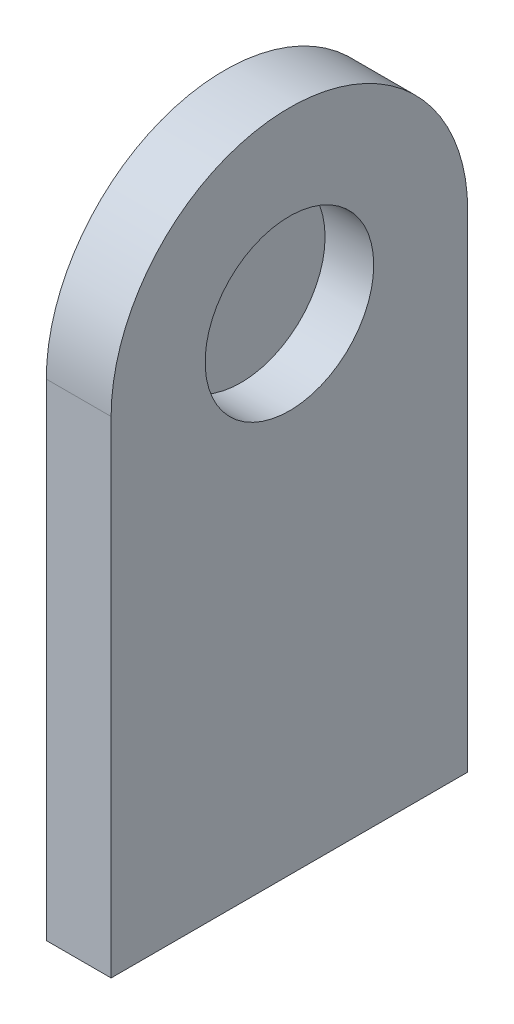
from build123d import *

# Parameters (mm, degrees)
BOSS_EXTRUDE1_DEPTH             = 20
SKETCH3_R                       = 26
CUT_EXTRUDE1_DEPTH              = 15
TAP_DRILL_FOR_M6X1_0_TAP2_D     = 5
TAP_DRILL_FOR_M6X1_0_TAP2_DEPTH = 40
TAP_DRILL_FOR_M6X1_0_TAP2_TIP   = 1.502151548


with BuildPart() as part:
    # Sketch2 → Boss-Extrude1 (new body)
    with BuildSketch(Plane(origin=(0, 0, 0), x_dir=(0, 0, -1), z_dir=(1, 0, 0))):
        with BuildLine():
            Line((55, -75), (55, 75))
            ThreePointArc((55, 75), (0, 20), (-55, 75))
            Line((-55, 75), (-55, -75))
            Line((-55, -75), (55, -75))
        make_face()
        with BuildLine():
            ThreePointArc((-55, 75), (0, 20), (55, 75))
            Line((55, 75), (-55, 75))
        make_face()
        with BuildLine():
            Line((-55, 75), (55, 75))
            ThreePointArc((55, 75), (0, 130), (-55, 75))
        make_face()
    extrude(amount=BOSS_EXTRUDE1_DEPTH)

    # Sketch3 → Cut-Extrude1 (cut)
    with BuildSketch(Plane(origin=(20, 0, 0), x_dir=(0, 0, -1), z_dir=(1, 0, 0))):
        with Locations((0, 75)):
            Circle(SKETCH3_R)
    extrude(amount=-CUT_EXTRUDE1_DEPTH, mode=Mode.SUBTRACT)

    # Tap Drill for M6x1.0 Tap2
    with Locations(Plane(origin=(0, -75, 0), x_dir=(-1, 0, 0), z_dir=(0, -1, 0))):
        with Locations((-10, -36.666666667), (-10, -18.333333333), (-10, 0), (-10, 18.333333333), (-10, 36.666666667)):
            Hole(TAP_DRILL_FOR_M6X1_0_TAP2_D / 2, depth=TAP_DRILL_FOR_M6X1_0_TAP2_DEPTH)
            with Locations((0, 0, -(TAP_DRILL_FOR_M6X1_0_TAP2_DEPTH + TAP_DRILL_FOR_M6X1_0_TAP2_TIP / 2))):  # 118° drill point
                Cone(0, TAP_DRILL_FOR_M6X1_0_TAP2_D / 2, TAP_DRILL_FOR_M6X1_0_TAP2_TIP, mode=Mode.SUBTRACT)


solid = part.part
